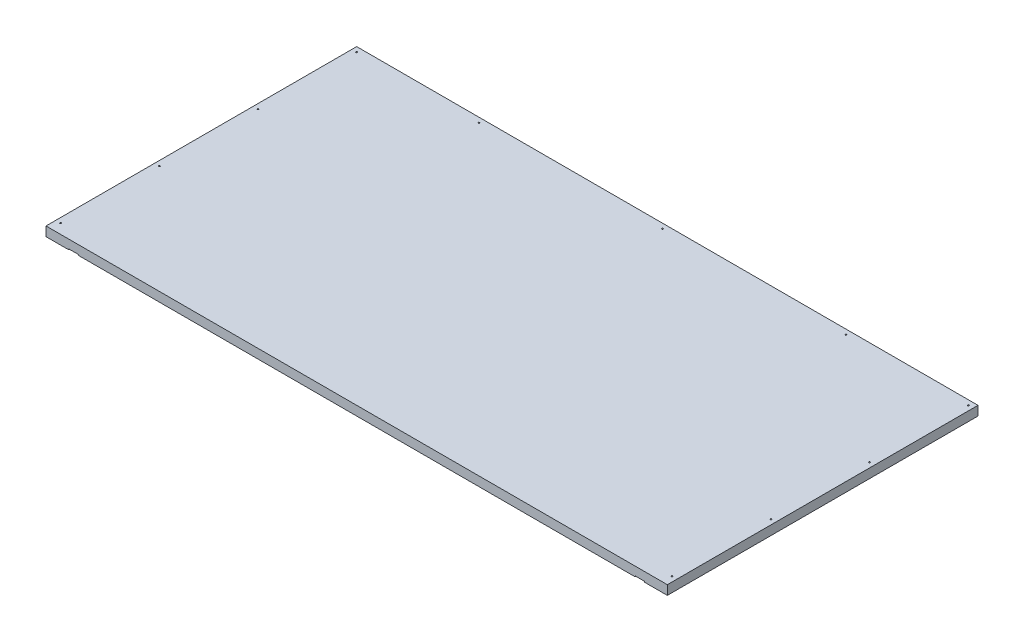
from build123d import *

# Parameters (mm, degrees)
SKETCH1_W           = 1219.2
SKETCH1_H           = 609.6
BOSS_EXTRUDE1_DEPTH = 18.25625
CUT_EXTRUDE1_DEPTH  = 1.5875
SKETCH8_R           = 1.397
CUT_EXTRUDE2_DEPTH  = 19.25625


with BuildPart() as part:
    # Sketch1 → Boss-Extrude1 (new body)
    with BuildSketch(Plane(origin=(0, 0, 0), x_dir=(1, 0, 0), z_dir=(0, 1, 0))):
        Rectangle(SKETCH1_W, SKETCH1_H)
    extrude(amount=BOSS_EXTRUDE1_DEPTH)

    # Sketch2 → Cut-Extrude1 (cut)
    with BuildSketch(Plane(origin=(0, 0, 0), x_dir=(1, 0, 0), z_dir=(0, 1, 0))):
        Polygon((-565.15, 304.8), (-546.1, 304.8), (-546.1, 9.525), (-120.65, 9.525), (-120.65, 304.8), (-101.6, 304.8), (-101.6, 9.525), (101.6, 9.525), (101.6, 304.8), (120.65, 304.8), (120.65, 9.525), (546.1, 9.525), (546.1, 304.8), (565.15, 304.8), (565.15, -304.8), (546.1, -304.8), (546.1, -9.525), (120.65, -9.525), (101.6, -9.525), (-101.6, -9.525), (-120.65, -9.525), (-546.1, -9.525), (-546.1, -304.8), (-565.15, -304.8), align=None)
    extrude(amount=CUT_EXTRUDE1_DEPTH, mode=Mode.SUBTRACT)

    # Sketch8 → Cut-Extrude2 (cut, through all)
    with BuildSketch(Plane(origin=(0, 18.25625, 0), x_dir=(1, 0, 0), z_dir=(0, 1, 0))):
        with Locations((-600.075, -285.75)):
            Circle(SKETCH8_R)
        with Locations((600.075, -285.75)):
            Circle(SKETCH8_R)
        with Locations((600.075, -92.075)):
            Circle(SKETCH8_R)
        with Locations((600.075, 101.6)):
            Circle(SKETCH8_R)
        with Locations((-360.045, 295.275)):
            Circle(SKETCH8_R)
        with Locations((0, 295.275)):
            Circle(SKETCH8_R)
        with Locations((360.045, 295.275)):
            Circle(SKETCH8_R)
        with Locations((600.075, 295.275)):
            Circle(SKETCH8_R)
        with Locations((-600.075, -92.075)):
            Circle(SKETCH8_R)
        with Locations((-600.075, 101.6)):
            Circle(SKETCH8_R)
        with Locations((-600.075, 295.275)):
            Circle(SKETCH8_R)
    extrude(amount=-CUT_EXTRUDE2_DEPTH, mode=Mode.SUBTRACT)


solid = part.part
